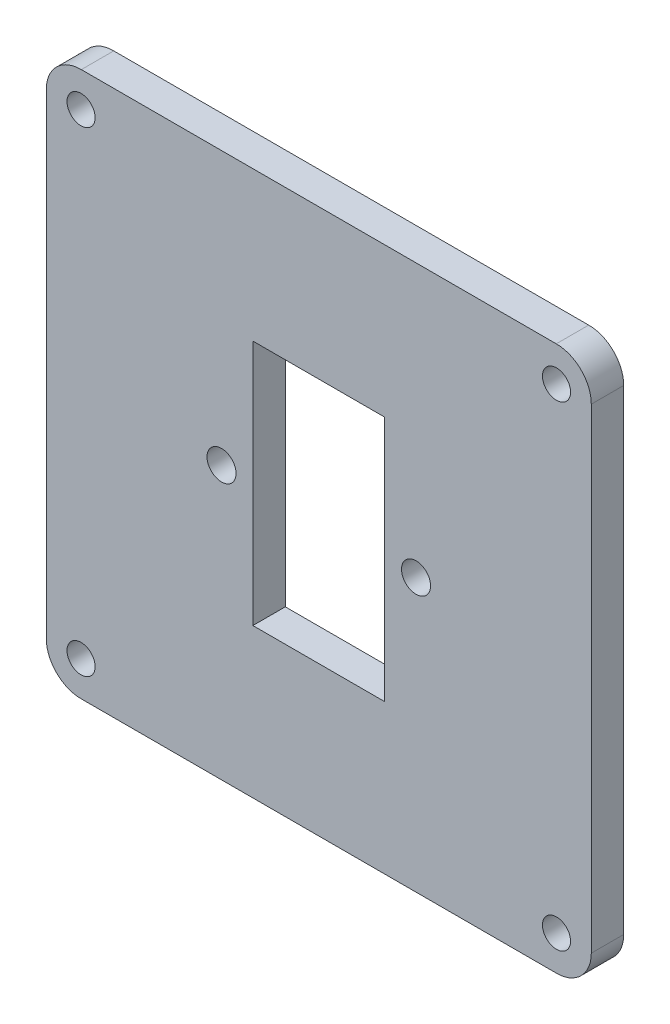
from build123d import *

# Parameters (mm, degrees)
MODEL_R             = 1.3
MODEL_R_2           = 1.344067797
MODEL_W             = 12.2
MODEL_H             = 22.8
BOSS_EXTRUDE1_DEPTH = 3


with BuildPart() as part:
    # Model → Boss-Extrude1 (new body)
    with BuildSketch(Plane.XY):
        with BuildLine():
            Line((25.639766947, 69.089607729), (69.59281779, 69.089607729))
            ThreePointArc((69.59281779, 69.089607729), (71.883249375, 68.155605213), (72.834203695, 65.872159696))
            Line((72.834203695, 65.872159696), (72.834203695, 21.872118121))
            ThreePointArc((72.834203695, 21.872118121), (71.882847983, 19.587552286), (69.590964861, 18.653962174))
            Line((69.590964861, 18.653962174), (25.641619876, 18.653962174))
            ThreePointArc((25.641619876, 18.653962174), (23.349724106, 19.587556709), (22.398372881, 21.872138909))
            Line((22.398372881, 21.872138909), (22.398372881, 65.872138909))
            ThreePointArc((22.398372881, 65.872138909), (23.349322718, 68.155600786), (25.639766947, 69.089607729))
        make_face()
        with Locations((25.616288319, 65.871777925)):
            Circle(MODEL_R, mode=Mode.SUBTRACT)
        with Locations((69.616288319, 65.871777925)):
            Circle(MODEL_R, mode=Mode.SUBTRACT)
        with Locations((56.616292368, 43.872138909)):
            Circle(MODEL_R_2, mode=Mode.SUBTRACT)
        with Locations((38.616292368, 43.872138909)):
            Circle(MODEL_R_2, mode=Mode.SUBTRACT)
        with Locations((25.616288319, 21.871777925)):
            Circle(MODEL_R, mode=Mode.SUBTRACT)
        with Locations((69.616288319, 21.871777925)):
            Circle(MODEL_R, mode=Mode.SUBTRACT)
        with Locations((47.616292368, 43.872138909)):
            Rectangle(MODEL_W, MODEL_H, mode=Mode.SUBTRACT)
    extrude(amount=BOSS_EXTRUDE1_DEPTH)


solid = part.part
